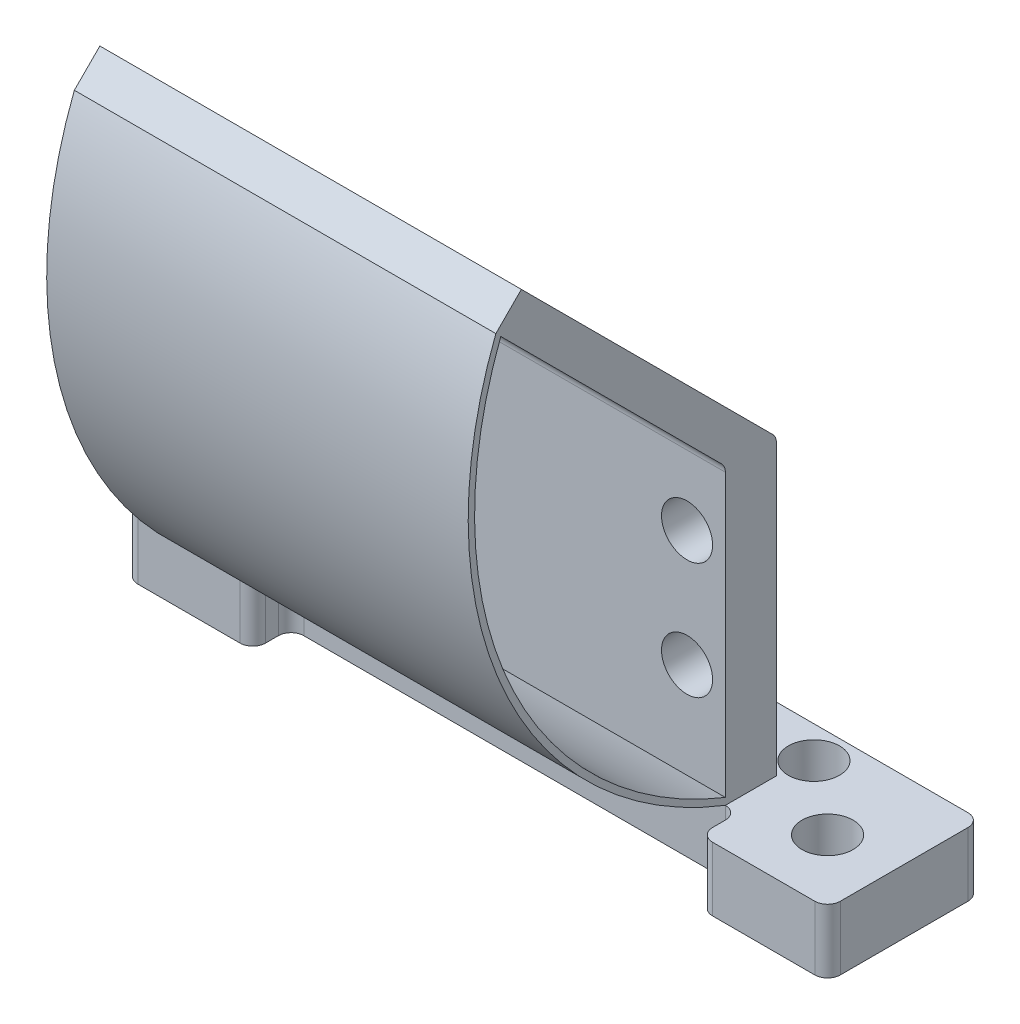
from build123d import *

# Parameters (mm, degrees)
EXTRUDE_2_DEPTH     = 5
SKETCH_4_W          = 33
SKETCH_4_H          = 4
EXTRUDE_3_DEPTH     = 23
EXTRUDE_4_DEPTH     = 33
SKETCH_11_R         = 2
CUT_EXTRUDE_1_DEPTH = 14
CUT_EXTRUDE_2_DEPTH = 33
SKETCH_17_R         = 2
CUT_EXTRUDE_3_DEPTH = 5
SKETCH_18_W         = 37
SKETCH_18_H         = 3
EXTRUDE_5_DEPTH     = 5
SKETCH_19_W         = 55
SKETCH_19_H         = 4.170749575
EXTRUDE_6_DEPTH     = 5
SKETCH_21_R         = 2
CUT_EXTRUDE_4_DEPTH = 5
FILLET_1_R          = 1
EXTRUDE_10_DEPTH    = 33


with BuildPart() as part:
    # 草图1 → 凸台-拉伸2 (new body)
    with BuildSketch(Plane(origin=(0, 0, 0), x_dir=(1, 0, 0), z_dir=(0, 1, 0))):
        with BuildLine():
            Line((26.533821687, -5), (18.533821687, -5))
            ThreePointArc((18.533821687, -5), (17.826714906, -4.707106781), (17.533821687, -4))
            Line((17.533821687, -4), (17.533821687, -3))
            ThreePointArc((17.533821687, -3), (17.240928468, -2.292893219), (16.533821687, -2))
            Line((16.533821687, -2), (-16.466178313, -2))
            ThreePointArc((-16.466178313, -2), (-17.173285094, -2.292893219), (-17.466178313, -3))
            Line((-17.466178313, -3), (-17.466178313, -4))
            ThreePointArc((-17.466178313, -4), (-17.759071532, -4.707106781), (-18.466178313, -5))
            Line((-18.466178313, -5), (-26.466178313, -5))
            ThreePointArc((-26.466178313, -5), (-27.173285094, -4.707106781), (-27.466178313, -4))
            Line((-27.466178313, -4), (-27.466178313, 4))
            ThreePointArc((-27.466178313, 4), (-27.173285094, 4.707106781), (-26.466178313, 5))
            Line((-26.466178313, 5), (-18.466178313, 5))
            ThreePointArc((-18.466178313, 5), (-17.759071532, 4.707106781), (-17.466178313, 4))
            Line((-17.466178313, 4), (-17.466178313, 3))
            ThreePointArc((-17.466178313, 3), (-17.173285094, 2.292893219), (-16.466178313, 2))
            Line((-16.466178313, 2), (16.533821687, 2))
            ThreePointArc((16.533821687, 2), (17.240928468, 2.292893219), (17.533821687, 3))
            Line((17.533821687, 3), (17.533821687, 4))
            ThreePointArc((17.533821687, 4), (17.826714906, 4.707106781), (18.533821687, 5))
            Line((18.533821687, 5), (26.533821687, 5))
            ThreePointArc((26.533821687, 5), (27.240928468, 4.707106781), (27.533821687, 4))
            Line((27.533821687, 4), (27.533821687, -4))
            ThreePointArc((27.533821687, -4), (27.240928468, -4.707106781), (26.533821687, -5))
        make_face()
    extrude(amount=EXTRUDE_2_DEPTH)

    # 草图4 → 凸台-拉伸3 (add)
    with BuildSketch(Plane(origin=(0, 5, 0), x_dir=(1, 0, 0), z_dir=(0, 1, 0))):
        with Locations((0.033821687, 0)):
            Rectangle(SKETCH_4_W, SKETCH_4_H)
    extrude(amount=EXTRUDE_3_DEPTH)

    # 草图5 → 凸台-拉伸4 (add)
    with BuildSketch(Plane.ZY.offset(16.466178313)):
        with BuildLine():
            ThreePointArc((2, 27.585786438), (2.076120467, 27.96846987), (2.292893219, 28.292893219))
            Line((2.292893219, 28.292893219), (19.970562748, 45.970562748))
            Line((19.970562748, 45.970562748), (17.970562748, 47.970562748))
            Line((17.970562748, 47.970562748), (-1.707106781, 28.292893219))
            ThreePointArc((-1.707106781, 28.292893219), (-1.821797126, 28.155566643), (-1.910179721, 28))
            Line((-1.910179721, 28), (2, 28))
            Line((2, 28), (2, 27.585786438))
        make_face()
    extrude(amount=-EXTRUDE_4_DEPTH)

    # 草图11 → 切除-拉伸1 (cut)
    with BuildSketch(Plane.XY.offset(2)):
        with Locations((13.533821687, 22.143107046)):
            Circle(SKETCH_11_R)
        with Locations((13.533821687, 13.028465829)):
            Circle(SKETCH_11_R)
        with BuildLine():
            Line((-11.034001398, 22.143107046), (-11.034001398, 13.028465829))
            ThreePointArc((-11.034001398, 13.028465829), (-12.750089855, 11.312377371), (-14.466178313, 13.028465829))
            Line((-14.466178313, 13.028465829), (-14.466178313, 22.143107046))
            ThreePointArc((-14.466178313, 22.143107046), (-12.750089855, 23.859195504), (-11.034001398, 22.143107046))
        make_face()
    extrude(amount=-CUT_EXTRUDE_1_DEPTH, mode=Mode.SUBTRACT)

    # 草图16 → 切除-拉伸2 (cut)
    with BuildSketch(Plane.ZY.offset(16.466178313)):
        with BuildLine():
            Line((-1.910179721, 28), (-2, 28))
            Line((-2, 28), (-2, 27.585786438))
            ThreePointArc((-2, 27.585786438), (-1.97728699, 27.797706563), (-1.910179721, 28))
        make_face()
    extrude(amount=-CUT_EXTRUDE_2_DEPTH, mode=Mode.SUBTRACT)

    # 草图17 → 切除-拉伸3 (cut)
    with BuildSketch(Plane(origin=(0, 5, 0), x_dir=(1, 0, 0), z_dir=(0, 1, 0))):
        with Locations((22.533821687, 0)):
            Circle(SKETCH_17_R)
        with Locations((-22.466178313, 0)):
            Circle(SKETCH_17_R)
    extrude(amount=-CUT_EXTRUDE_3_DEPTH, mode=Mode.SUBTRACT)

    # 草图18 → 凸台-拉伸5 (add)
    with BuildSketch(Plane.XZ):
        with Locations((0.033821687, -3.5)):
            Rectangle(SKETCH_18_W, SKETCH_18_H)
    extrude(amount=-EXTRUDE_5_DEPTH)

    # 草图19 → 凸台-拉伸6 (add)
    with BuildSketch(Plane.XZ):
        with Locations((0.033821687, -4.914625212)):
            Rectangle(SKETCH_19_W, SKETCH_19_H)
    extrude(amount=-EXTRUDE_6_DEPTH)

    # 草图21 → 切除-拉伸4 (cut)
    with BuildSketch(Plane.XZ):
        with Locations((-16.966178313, -4.5)):
            Circle(SKETCH_21_R)
        with Locations((16.966178313, -4.5)):
            Circle(SKETCH_21_R)
    extrude(amount=-CUT_EXTRUDE_4_DEPTH, mode=Mode.SUBTRACT)

    # 圆角1
    fillet_1_edges = [part.edges().sort_by_distance(p)[0] for p in [
        (27.533821687, 2.5, -7),
        (-27.466178313, 2.5, -7),
    ]]
    fillet(fillet_1_edges, radius=FILLET_1_R)

    # 草图29 → 凸台-拉伸10 (add)
    with BuildSketch(Plane(origin=(16.533821687, 0, 0), x_dir=(0, 0, -1), z_dir=(1, 0, 0))):
        with BuildLine():
            Line((-2, 5.537377417), (-2, 5))
            ThreePointArc((-2, 5), (-19.470562748, 21.763455967), (-19.970562748, 45.970562748))
            Line((-19.970562748, 45.970562748), (-19.583896385, 45.583896385))
            ThreePointArc((-19.583896385, 45.583896385), (-19.007789844, 21.953169584), (-2, 5.537377417))
        make_face()
    extrude(amount=-EXTRUDE_10_DEPTH)


solid = part.part
